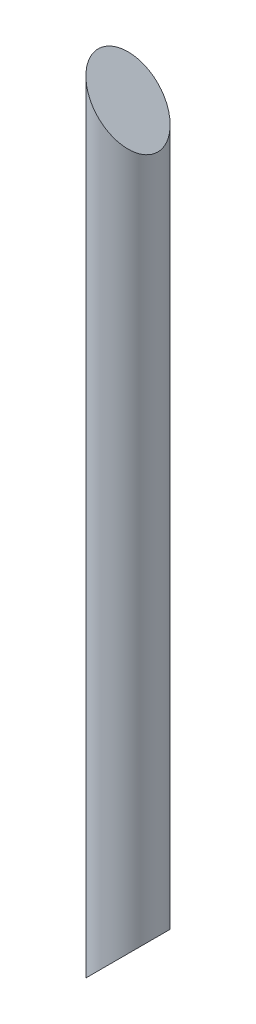
from build123d import *

# Parameters (mm, degrees)
SKETCH1_R               = 31.75
BOSS_EXTRUDE1_DEPTH     = 723.9
SKETCH4_R               = 31.75
BOSS_EXTRUDE2_DEPTH     = 63.5
BOSS_EXTRUDE3_START     = 63.5
SKETCH5_R               = 31.75
BOSS_EXTRUDE3_DEPTH     = 63.5
CUT_EXTRUDE2_DEPTH      = 63.5
CUT_EXTRUDE2_DEPTH_BACK = 63.5


with BuildPart() as part:
    # Sketch1 → Boss-Extrude1 (new body)
    with BuildSketch(Plane(origin=(0, 0, 0), x_dir=(1, 0, 0), z_dir=(0, 1, 0))):
        Circle(SKETCH1_R)
    extrude(amount=BOSS_EXTRUDE1_DEPTH)

    # Sketch4 → Boss-Extrude2 (add)
    with BuildSketch(Plane(origin=(0, 723.9, 0), x_dir=(1, 0, 0), z_dir=(0, 1, 0))):
        Circle(SKETCH4_R)
    extrude(amount=BOSS_EXTRUDE2_DEPTH)

    # Sketch5 → Boss-Extrude3 (add)
    with BuildSketch(Plane.XZ.offset(BOSS_EXTRUDE3_START)):
        Circle(SKETCH5_R)
    extrude(amount=-BOSS_EXTRUDE3_DEPTH)

    # Sketch2 → Cut-Extrude2 (cut, two sides: drawn at the far end of the back side and taken through both)
    with BuildSketch(Plane.XY.offset(-CUT_EXTRUDE2_DEPTH_BACK)):
        Polygon((-31.75, 787.4), (31.75, 723.9), (31.75, 787.4), align=None)
        Polygon((31.75, -63.5), (31.75, 0), (-31.75, -63.5), align=None)
    extrude(amount=CUT_EXTRUDE2_DEPTH + CUT_EXTRUDE2_DEPTH_BACK, mode=Mode.SUBTRACT)


solid = part.part
